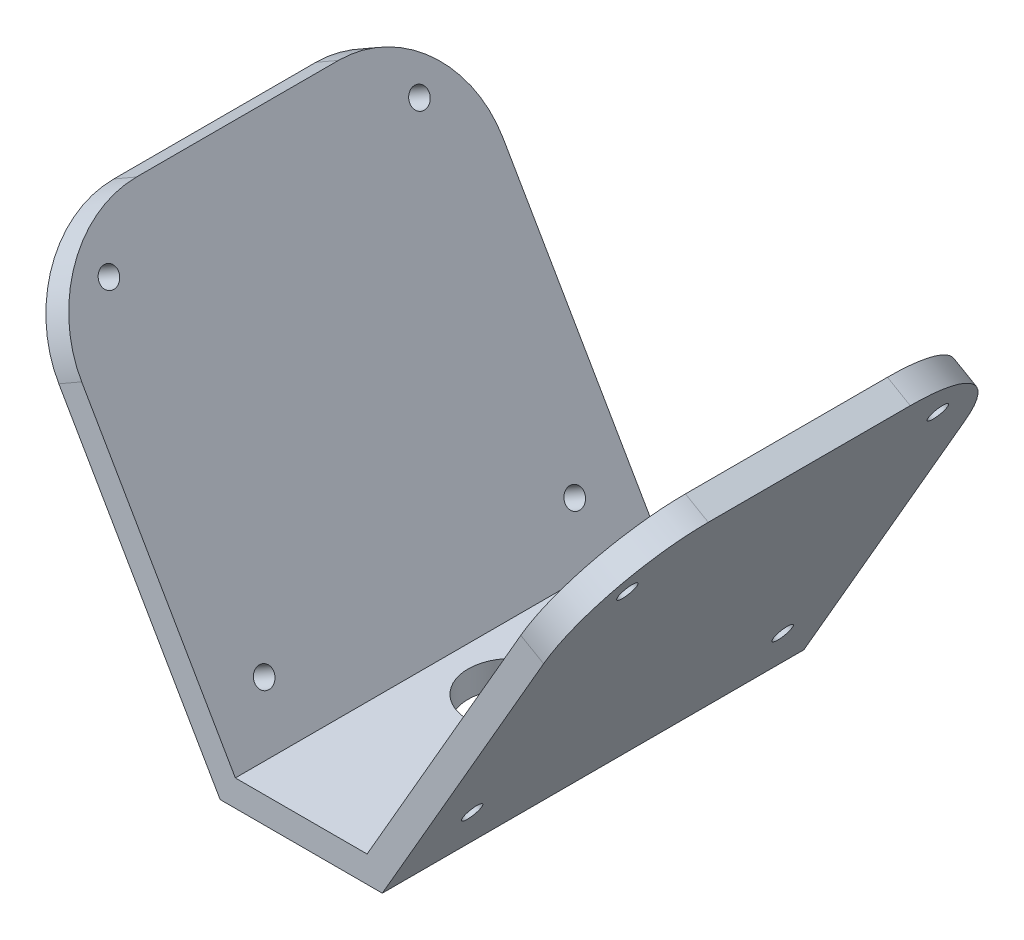
from build123d import *

# Parameters (mm, degrees)
BOSS_EXTRU_1_DEPTH      = 48
BOSS_EXTRU_1_DEPTH_BACK = 48
ESQUISSE2_R             = 2.2
ENL_V_MAT_EXTRU_1_DEPTH = 10
CONG_1_R                = 25
ECHELLE1_SCALE          = 0.5
ESQUISSE3_R             = 5
ENL_V_MAT_EXTRU_2_DEPTH = 10


with BuildPart() as part:
    # Esquisse1 → Boss.-Extru.1 (new, two sides: drawn at the far end of the back side and taken through both)
    with BuildSketch(Plane.XY.offset(-BOSS_EXTRU_1_DEPTH_BACK)):
        Polygon((15, 0), (-15, 0), (-62.5, 82.27241336), (-67.696152423, 79.27241336), (-18.464101615, -6), (18.464101615, -6), (67.696152423, 79.27241336), (62.5, 82.27241336), align=None)
    extrude(amount=BOSS_EXTRU_1_DEPTH + BOSS_EXTRU_1_DEPTH_BACK)

    # Esquisse2 → Enlèv. mat.-Extru.1 (cut)
    with BuildSketch(Plane(origin=(-16.446152423, -9.495190528, 0), x_dir=(0, 0, 1), z_dir=(-0.8660254037844378, -0.5000000000000016, 0))):
        with Locations((-35.355339059, 19.644660941)):
            Circle(ESQUISSE2_R)
        with Locations((35.355339059, 90.355339059)):
            Circle(ESQUISSE2_R)
        with Locations((35.355339059, 19.644660941)):
            Circle(ESQUISSE2_R)
        with Locations((-35.355339059, 90.355339059)):
            Circle(ESQUISSE2_R)
    enl_v_mat_extru_1 = extrude(amount=-ENL_V_MAT_EXTRU_1_DEPTH, mode=Mode.SUBTRACT)

    # Congé1
    cong_1_edges = [part.edges().sort_by_distance(p)[0] for p in [
        (65.098076211, 80.77241336, 48),
        (65.098076211, 80.77241336, -48),
        (-65.098076211, 80.77241336, -48),
        (-65.098076211, 80.77241336, 48),
    ]]
    fillet(cong_1_edges, radius=CONG_1_R)

    # Symétrie1: Enlèv. mat.-Extru.1 across plane
    add(enl_v_mat_extru_1.mirror(Plane(origin=(0, 0, 0), x_dir=(0, 0, 1), z_dir=(1, 0, 0))), mode=Mode.SUBTRACT)


with BuildPart() as part_1:
    # Echelle1: scaled about (0, 0, 0)
    add(part.part.scale(ECHELLE1_SCALE))

    # Esquisse3 → Enlèv. mat.-Extru.2 (cut)
    with BuildSketch(Plane(origin=(0, 0, 0), x_dir=(1, 0, 0), z_dir=(0, 1, 0))):
        Circle(ESQUISSE3_R)
    extrude(amount=-ENL_V_MAT_EXTRU_2_DEPTH, mode=Mode.SUBTRACT)


solid = part_1.part
